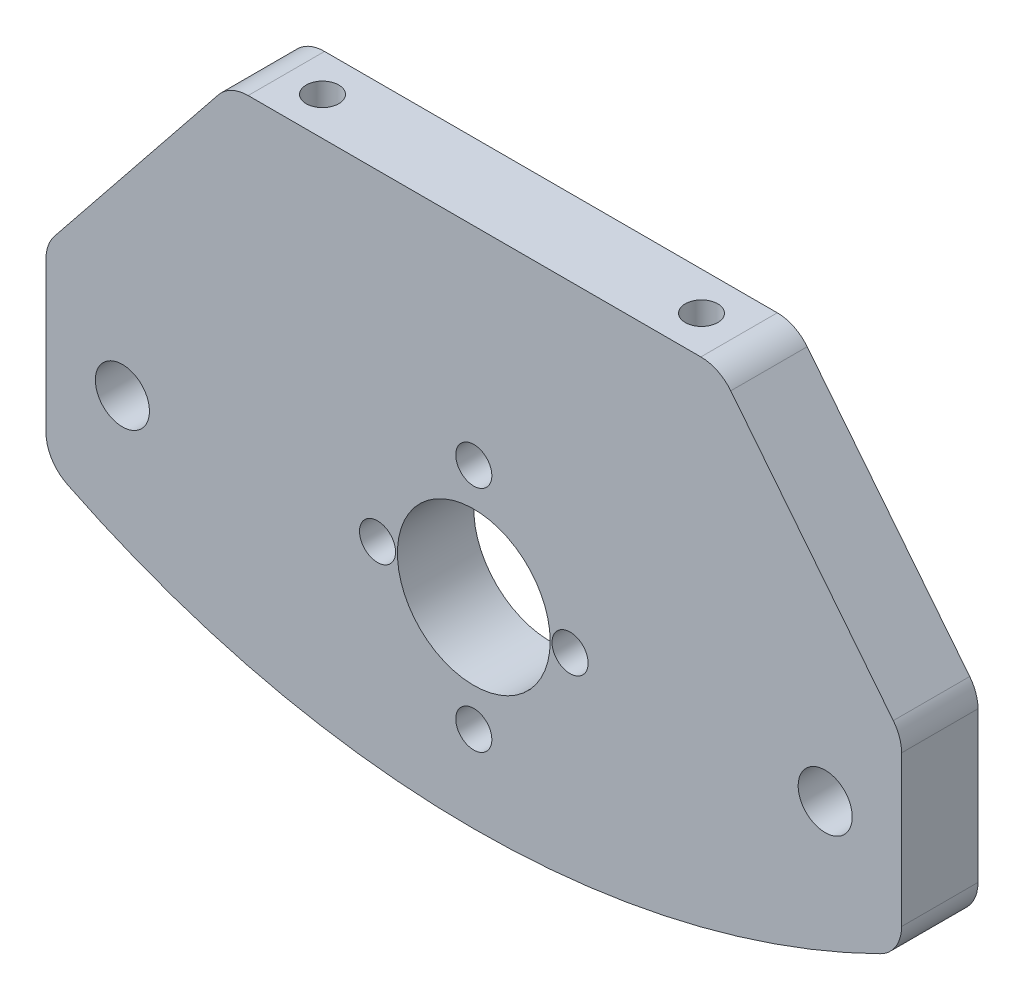
from build123d import *

# Parameters (mm, degrees)
SKETCH1_W                 = 71.11
SKETCH1_H                 = 53.65
SKETCH1_R                 = 6.35
SKETCH1_R_2               = 1.5
BOSS_EXTRUDE1_DEPTH       = 6.35
F_8_CLEARANCE_HOLE1_D     = 4.4958
F_6_32_TAPPED_HOLE1_D     = 2.7051
F_6_32_TAPPED_HOLE1_DEPTH = 25.4
F_6_32_TAPPED_HOLE1_TIP   = 0.81269403
CUT_EXTRUDE1_DEPTH        = 7.35
FILLET1_R                 = 3.175


with BuildPart() as part:
    # Sketch1 → Boss-Extrude1 (new body)
    with BuildSketch(Plane.XY):
        with Locations((0, -0.090978152)):
            Rectangle(SKETCH1_W, SKETCH1_H)
        Circle(SKETCH1_R, mode=Mode.SUBTRACT)
        with Locations((-8, 0)):
            Circle(SKETCH1_R_2, mode=Mode.SUBTRACT)
        with Locations((0, 9.5)):
            Circle(SKETCH1_R_2, mode=Mode.SUBTRACT)
        with Locations((8, 0)):
            Circle(SKETCH1_R_2, mode=Mode.SUBTRACT)
        with Locations((0, -9.5)):
            Circle(SKETCH1_R_2, mode=Mode.SUBTRACT)
    extrude(amount=BOSS_EXTRUDE1_DEPTH)

    # #8 Clearance Hole1 (through all)
    with Locations(Plane(origin=(0, 0, 0), x_dir=(-1, 0, 0), z_dir=(0, 0, -1))):
        with Locations((-29.205, -0.090978152), (29.205, -0.090978152)):
            Hole(F_8_CLEARANCE_HOLE1_D / 2)

    # #6-32 Tapped Hole1
    with Locations(Plane(origin=(0, 26.734021848, 0), x_dir=(1, 0, 0), z_dir=(0, 1, 0))):
        with Locations((15.75, -3.175), (-15.75, -3.175)):
            Hole(F_6_32_TAPPED_HOLE1_D / 2, depth=F_6_32_TAPPED_HOLE1_DEPTH)
            with Locations((0, 0, -(F_6_32_TAPPED_HOLE1_DEPTH + F_6_32_TAPPED_HOLE1_TIP / 2))):  # 118° drill point
                Cone(0, F_6_32_TAPPED_HOLE1_D / 2, F_6_32_TAPPED_HOLE1_TIP, mode=Mode.SUBTRACT)

    # Sketch7 → Cut-Extrude1 (cut, through all)
    with BuildSketch(Plane(origin=(0, 0, 0), x_dir=(-1, 0, 0), z_dir=(0, 0, -1))):
        Polygon((-35.555, 26.734021848), (-35.555, 7.684021848), (-20.40455, 26.734021848), align=None)
        Polygon((35.555, 26.734021848), (20.27755, 26.734021848), (35.555, 7.684021848), align=None)
        with BuildLine():
            Line((-35.555, -26.915978152), (35.555, -26.915978152))
            Line((35.555, -26.915978152), (35.555, -7.865978152))
            ThreePointArc((35.555, -7.865978152), (0, -16.669524425), (-35.555, -7.865978152))
            Line((-35.555, -7.865978152), (-35.555, -26.915978152))
        make_face()
    extrude(amount=-CUT_EXTRUDE1_DEPTH, mode=Mode.SUBTRACT)

    # Fillet1
    fillet1_edges = [part.edges().sort_by_distance(p)[0] for p in [
        (35.555, 7.684021848, 3.175),
        (20.40455, 26.734021848, 3.175),
        (-20.27755, 26.734021848, 3.175),
        (-35.555, 7.684021848, 3.175),
        (35.555, -7.865978152, 3.175),
        (-35.555, -7.865978152, 3.175),
    ]]
    fillet(fillet1_edges, radius=FILLET1_R)


solid = part.part
